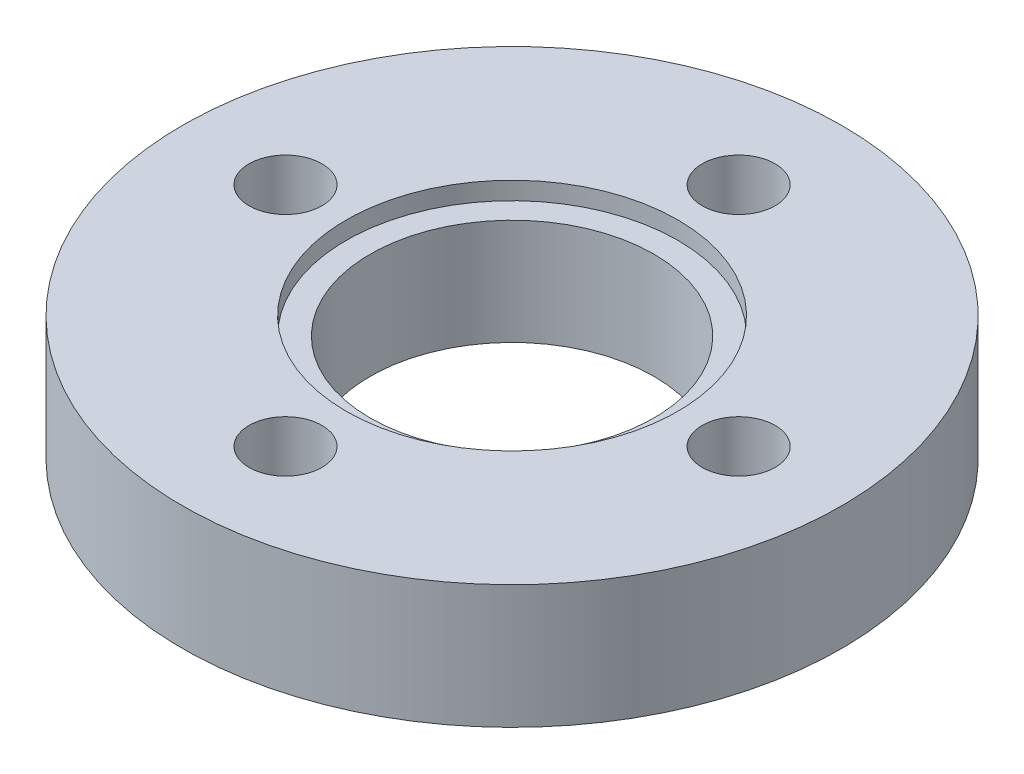
from build123d import *

# Parameters (mm, degrees)
F_8_CLEARANCE_HOLE1_D = 4.4958


with BuildPart() as part:
    # Sketch1 → Revolve1 (revolve)
    with BuildSketch(Plane.XY):
        Polygon((-20.32, 7.62), (-20.32, 0), (-8.7503, 0), (-8.7503, 6.5278), (-10.2235, 6.5278), (-10.2235, 7.62), align=None)
    revolve(axis=Axis((0, 0, 0), (0, 1, 0)))

    # #8 Clearance Hole1 (through all)
    with Locations(Plane(origin=(0, 7.62, 0), x_dir=(1, 0, 0), z_dir=(0, 1, 0))):
        with Locations((13.97, 0), (0, 13.97), (-13.97, 0), (0, -13.97)):
            Hole(F_8_CLEARANCE_HOLE1_D / 2)


solid = part.part
